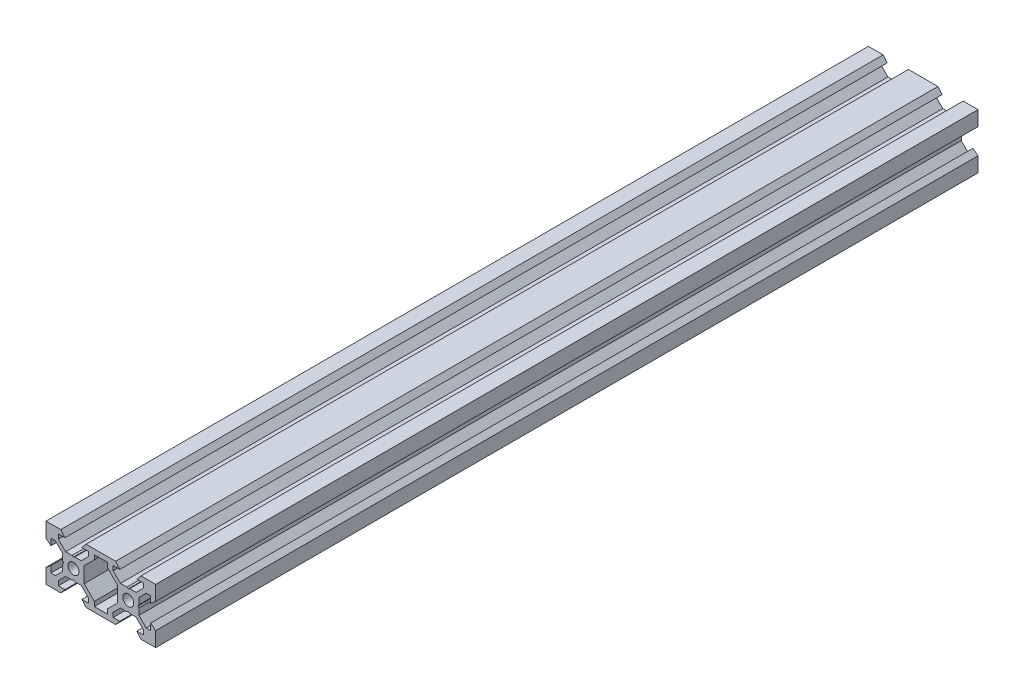
from build123d import *

# Parameters (mm, degrees)
SKETCH1_R           = 2
BOSS_EXTRUDE1_DEPTH = 300


with BuildPart() as part:
    # Sketch1 → Boss-Extrude1 (new body)
    with BuildSketch(Plane.XY):
        Polygon((-5.389620664, 10), (5.389620664, 10), (6.9, 8.2), (4.5, 8.2), (4.5, 6.556171609), (7.151917065, 3.899773171), (9.480384758, 3.899773171), (10, 3.599773171), (10.519615242, 3.899773171), (12.848082935, 3.899773171), (15.5, 6.556171609), (15.5, 8.2), (13.1, 8.2), (14.610379336, 10), (20, 10), (20, 4.610379336), (18.2, 3.1), (18.2, 5.5), (16.556171609, 5.5), (13.9, 2.839339828), (13.9, 0.519615231), (13.599999981, 0), (13.9, -0.519615231), (13.9, -2.839339828), (16.556171609, -5.5), (18.2, -5.5), (18.2, -3.1), (20, -4.610379336), (20, -10), (14.610379336, -10), (13.1, -8.2), (15.5, -8.2), (15.5, -6.556171609), (12.839339828, -3.9), (10.519222362, -3.9), (10, -3.600226829), (9.480777638, -3.9), (7.160660172, -3.9), (4.5, -6.556171609), (4.5, -8.2), (6.9, -8.2), (5.389620664, -10), (-5.389620664, -10), (-6.9, -8.2), (-4.5, -8.2), (-4.5, -6.556171609), (-7.160432959, -3.900226829), (-9.480384758, -3.900226829), (-10, -3.600226829), (-10.519615242, -3.900226829), (-12.839339828, -3.9), (-15.5, -6.556171609), (-15.5, -8.2), (-13.1, -8.2), (-14.610379336, -10), (-20, -10), (-20, -4.610379336), (-18.2, -3.1), (-18.2, -5.5), (-16.556171609, -5.5), (-13.9, -2.839339828), (-13.9, -0.519615231), (-13.599999981, 0), (-13.9, 0.519615231), (-13.9, 2.839339828), (-16.556171609, 5.5), (-18.2, 5.5), (-18.2, 3.1), (-20, 4.610379336), (-20, 10), (-14.610379336, 10), (-13.1, 8.2), (-15.5, 8.2), (-15.5, 6.556171609), (-12.839339828, 3.9), (-10.519615242, 3.899773171), (-10, 3.599773171), (-9.480384758, 3.899773171), (-7.160660172, 3.9), (-4.5, 6.556171609), (-4.5, 8.2), (-6.9, 8.2), align=None)
        with Locations((-10, 0)):
            Circle(SKETCH1_R, mode=Mode.SUBTRACT)
        with Locations((10, 0)):
            Circle(SKETCH1_R, mode=Mode.SUBTRACT)
        Polygon((-6.1, -2.839339828), (-2.376887287, -6.556171609), (-2.376887287, -8.2), (2.376887287, -8.2), (2.376887287, -6.556171609), (6.1, -2.839339828), (6.1, 2.839339828), (2.383168219, 6.556171609), (2.383168219, 8.2), (-2.383168219, 8.2), (-2.383168219, 6.556171609), (-6.1, 2.839339828), align=None, mode=Mode.SUBTRACT)
    extrude(amount=BOSS_EXTRUDE1_DEPTH)


solid = part.part
